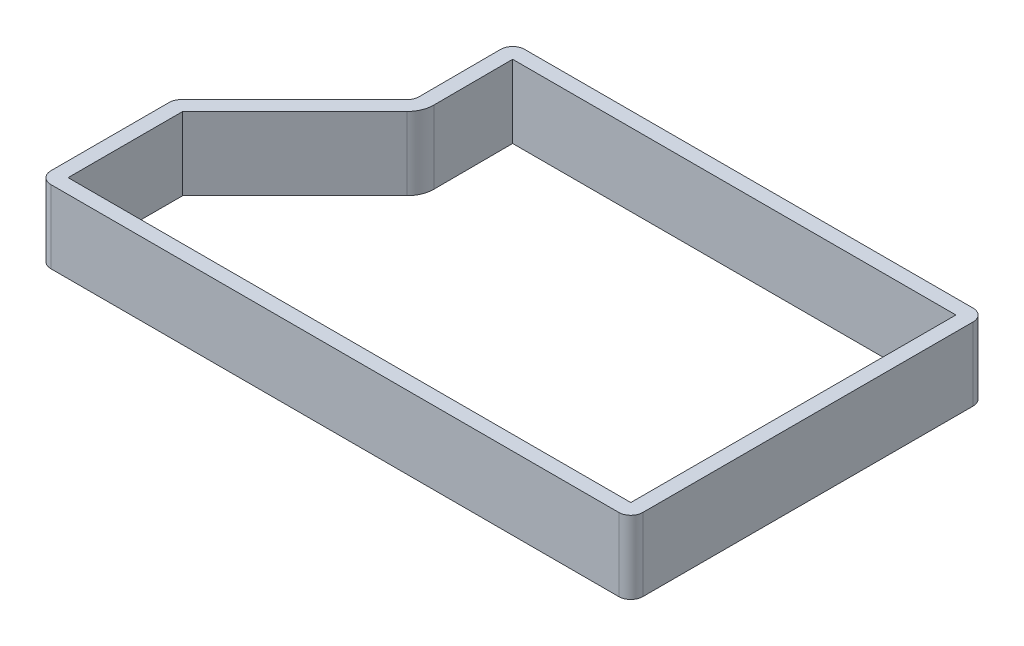
from build123d import *

# Parameters (mm, degrees)
EXTRUDE_THIN1_DEPTH = 10


with BuildPart() as part:
    # Sketch1 → Extrude-Thin1 (new body)
    with BuildSketch(Plane(origin=(0, 0, 0), x_dir=(1, 0, 0), z_dir=(0, 1, 0))):
        with BuildLine():
            Line((-48.055213063, -4.381670713), (-48.055213063, -20.589409576))
            ThreePointArc((-48.055213063, -20.589409576), (-47.571938312, -21.756136971), (-46.405210296, -22.239410221))
            Line((-46.405210296, -22.239410221), (31.434177514, -22.239310121))
            ThreePointArc((31.434177514, -22.239310121), (32.600656469, -21.756281638), (33.08417589, -20.590006097))
            Line((33.08417589, -20.590006097), (33.103278784, 24.656648645))
            ThreePointArc((33.103278784, 24.656648645), (32.62001265, 25.824064412), (31.452603406, 26.307346307))
            Line((31.452603406, 26.307346307), (-29.991737035, 26.282239879))
            ThreePointArc((-29.991737035, 26.282239879), (-31.133079443, 25.823165706), (-31.639590763, 24.702068979))
            Line((-31.639590763, 24.702068979), (-31.602092863, 13.443859379))
            ThreePointArc((-31.602092863, 13.443859379), (-31.726631593, 12.809477673), (-32.0853545, 12.271641341))
            Line((-32.0853545, 12.271641341), (-47.571938464, -3.214942622))
            ThreePointArc((-47.571938464, -3.214942622), (-47.929614086, -3.75024202), (-48.055213063, -4.381670713))
        make_face()
        with BuildLine():
            Line((-46.055213063, -4.526644346), (-46.055213063, -20.239409771))
            Line((-46.055213063, -20.239409771), (31.084323774, -20.239310571))
            Line((31.084323774, -20.239310571), (31.103131072, 24.307203344))
            Line((31.103131072, 24.307203344), (-29.638181818, 24.282384176))
            Line((-29.638181818, 24.282384176), (-29.602103962, 13.4505225))
            ThreePointArc((-29.602103962, 13.4505225), (-29.877600157, 12.047189835), (-30.671140938, 10.857427779))
            Line((-30.671140938, 10.857427779), (-46.055213063, -4.526644346))
        make_face(mode=Mode.SUBTRACT)
    extrude(amount=EXTRUDE_THIN1_DEPTH)


solid = part.part
